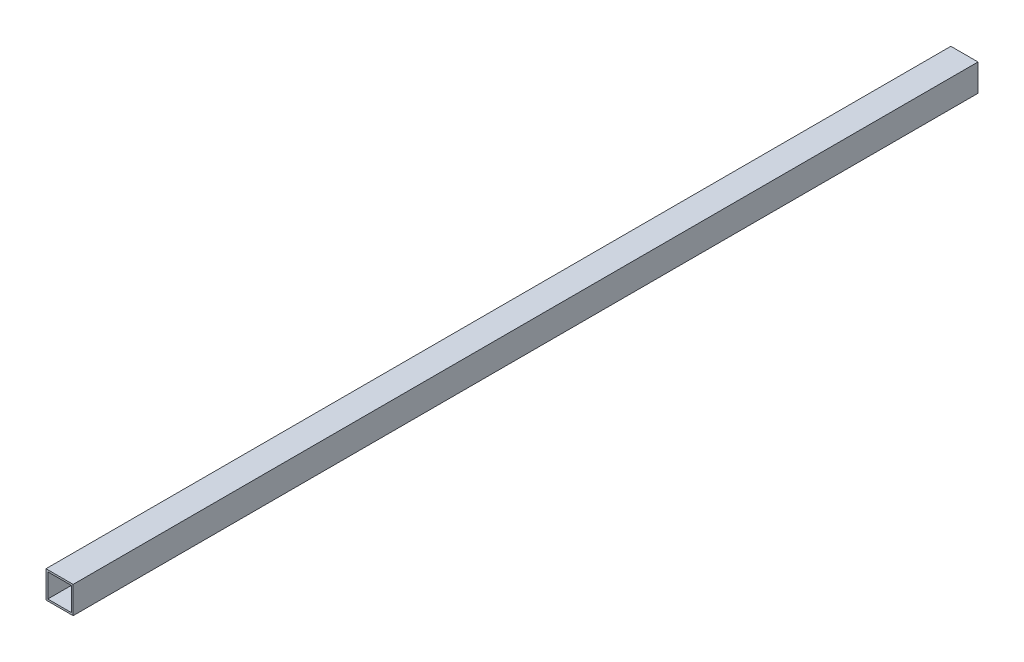
from build123d import *

# Parameters (mm, degrees)
SKETCH1_W   = 60
SKETCH1_H   = 60
SKETCH1_W_2 = 52
SKETCH1_H_2 = 52


with BuildPart() as part:
    # Sweep1: sweep along a curve in space
    with BuildLine() as sweep1_path:
        add(Edge.make_bspline(
            [(0, 0, 0), (0, 0, 2000)],
            knots=[0, 0, 1, 1], degree=1))
    # Sketch1 → Sweep1 (sweep)
    with BuildSketch(Plane.XY):
        Rectangle(SKETCH1_W, SKETCH1_H)
        Rectangle(SKETCH1_W_2, SKETCH1_H_2, mode=Mode.SUBTRACT)
    sweep(path=sweep1_path.line)


solid = part.part
